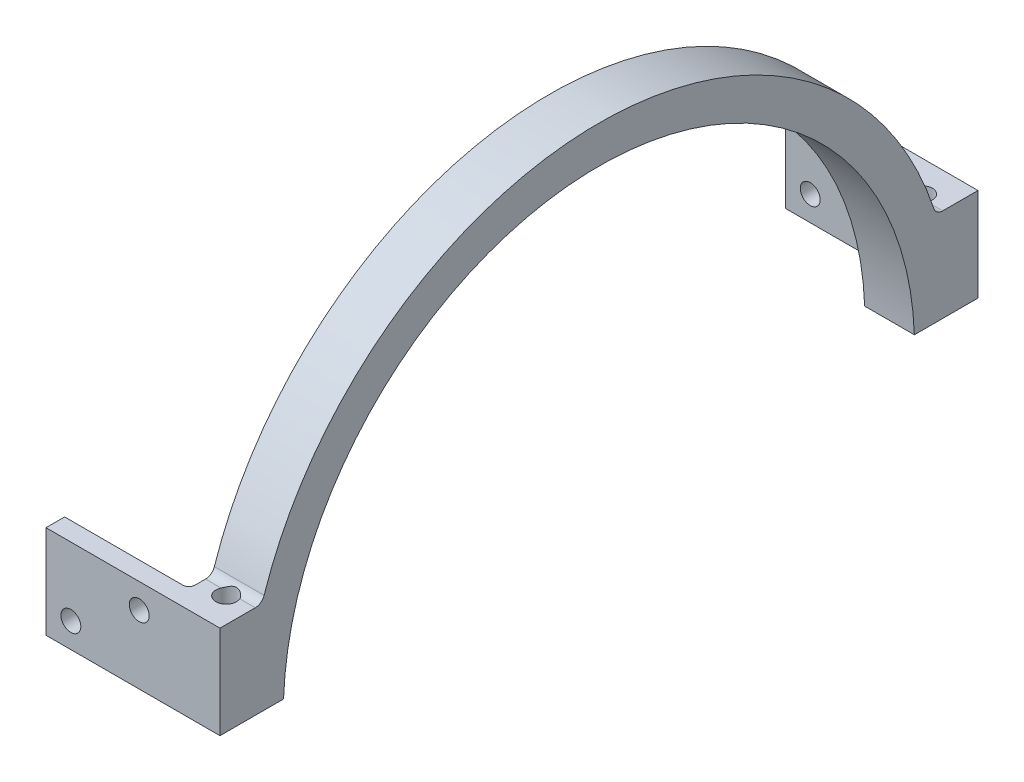
from build123d import *

# Parameters (mm, degrees)
BOSS_EXTRUDE1_DEPTH           = 8
M4_TAPPED_HOLE1_D             = 3.3
SKETCH8_W                     = 20
SKETCH8_H                     = 15
BOSS_EXTRUDE2_DEPTH           = 3
FILLET1_R                     = 1
M3_CLEARANCE_HOLE1_AT_2_COUNT = 2
M3_CLEARANCE_HOLE1_AT_2_PITCH = 13.03840481
FILLET1_OF_MIRROR1_R          = 1


with BuildPart() as part:
    # Sketch1 → Boss-Extrude1 (new body)
    with BuildSketch(Plane(origin=(0, 0, 0), x_dir=(0, 0, -1), z_dir=(1, 0, 0))):
        with BuildLine():
            Line((-60.995543931, 1.9), (-50.764456069, 1.9))
            ThreePointArc((-50.764456069, 1.9), (0, 50.8), (50.764456069, 1.9))
            Line((50.764456069, 1.9), (61.004456069, 1.9))
            Line((61.004456069, 1.9), (61.004456069, 16.9))
            Line((61.004456069, 16.9), (55.320249457, 16.9))
            ThreePointArc((55.320249457, 16.9), (54.442787227, 17.18342282), (53.896915423, 17.926586621))
            ThreePointArc((53.896915423, 17.926586621), (0, 56.8), (-53.896915423, 17.926586621))
            ThreePointArc((-53.896915423, 17.926586621), (-54.442787227, 17.18342282), (-55.320249457, 16.9))
            Line((-55.320249457, 16.9), (-60.995543931, 16.9))
            Line((-60.995543931, 16.9), (-60.995543931, 1.9))
        make_face()
    extrude(amount=BOSS_EXTRUDE1_DEPTH)

    # M4 Tapped Hole1 (through all)
    with Locations(Plane.XZ.offset(-1.9)):
        with Locations((4, -56.004456069), (4, 55.995543931)):
            Hole(M4_TAPPED_HOLE1_D / 2)

    # Sketch8 → Boss-Extrude2 (add)
    with BuildSketch(Plane.XY.offset(60.995543931)):
        with Locations((-10, 9.4)):
            Rectangle(SKETCH8_W, SKETCH8_H)
    boss_extrude2 = extrude(amount=-BOSS_EXTRUDE2_DEPTH)

    # Fillet1
    fillet1_edges = [part.edges().sort_by_distance(p)[0] for p in [
        (0, 9.4, 57.995543931),
    ]]
    fillet(fillet1_edges, radius=FILLET1_R)

    # Sketch9 → M3 Clearance Hole1 (revolve, cut)
    with BuildSketch(Plane(origin=(-5, 12.9, 57.995543931), x_dir=(0, 1, 0), z_dir=(1, 0, 0))):
        Polygon((0, 0), (0, 15.96137699), (1.6, 15), (1.6, 0), align=None)
    m3_clearance_hole1 = revolve(axis=Axis((-5, 12.9, 51.645543931), (0, 0, 1)), mode=Mode.SUBTRACT)

    # M3 Clearance Hole1 at 2: M3 Clearance Hole1 ×2
    with Locations(*[Vector(-0.8436614877321075, -0.5368754921931593, 0) * (i * M3_CLEARANCE_HOLE1_AT_2_PITCH) for i in range(1, M3_CLEARANCE_HOLE1_AT_2_COUNT)]):
        add(m3_clearance_hole1, mode=Mode.SUBTRACT)

    # Mirror1: Boss-Extrude2, M3 Clearance Hole1 across plane
    add(boss_extrude2.mirror(Plane(origin=(0, 0, -0.004456069), x_dir=(1, 0, 0), z_dir=(0, 0, -1))))
    add(m3_clearance_hole1.mirror(Plane(origin=(0, 0, -0.004456069), x_dir=(1, 0, 0), z_dir=(0, 0, -1))), mode=Mode.SUBTRACT)

    # Mirror1 copy 1 sketch → Mirror1 copy 1 (revolve, cut)
    with BuildSketch(Plane(origin=(-16, 5.9, -58.004456069), x_dir=(0, 1, 0), z_dir=(1, 0, 0))):
        Polygon((0, 0), (0, -15.96137699), (1.6, -15), (1.6, 0), align=None)
    revolve(axis=Axis((-16, 5.9, -51.654456069), (0, 0, 1)), mode=Mode.SUBTRACT)

    # Fillet1 of Mirror1
    fillet1_of_mirror1_edges = [part.edges().sort_by_distance(p)[0] for p in [
        (0, 9.4, -58.004456069),
    ]]
    fillet(fillet1_of_mirror1_edges, radius=FILLET1_OF_MIRROR1_R)


solid = part.part
